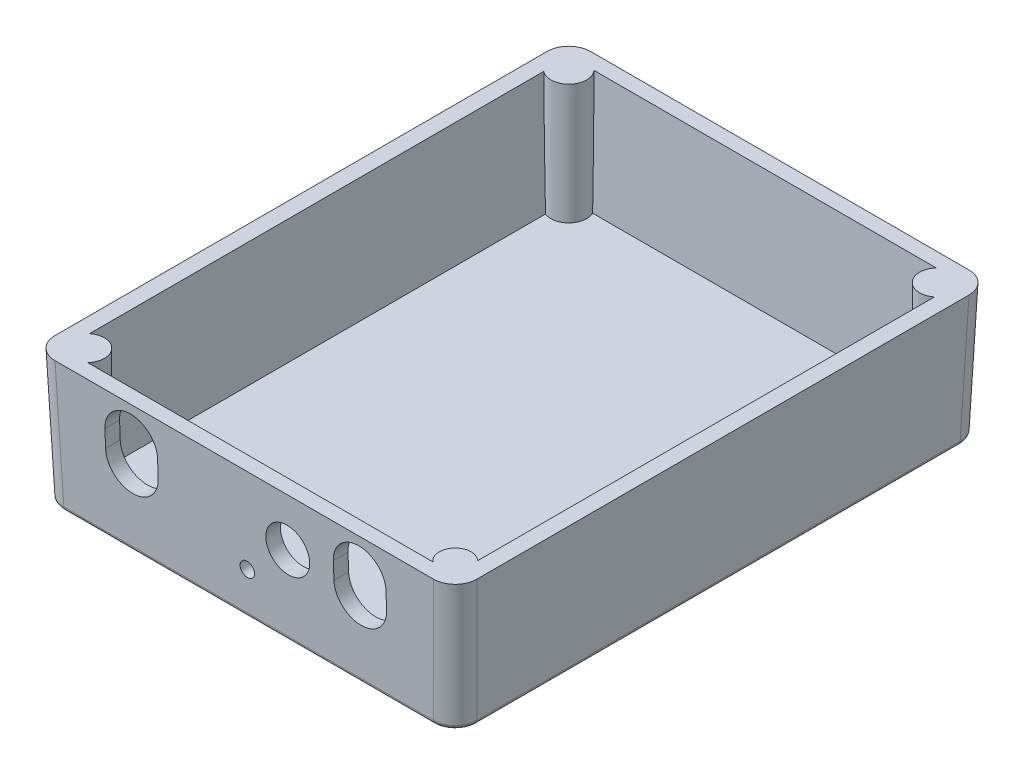
from build123d import *

# Parameters (mm, degrees)
SKETCH1_W               = 94.1
SKETCH1_H               = 120
BOSS_EXTRUDE1_DEPTH     = 29.82
BOSS_EXTRUDE1_TAPER     = -2
FILLET1_R               = 4.95
SKETCH3_W               = 89.06
SKETCH3_H               = 115.4
CUT_EXTRUDE1_DEPTH      = 27.4
CUT_EXTRUDE1_TAPER      = 2
SKETCH4_R               = 4.065
SKETCH4_R_2             = 3.612475726
BOSS_EXTRUDE2_DEPTH     = 29.82
CUT_EXTRUDE2_START      = 3
SKETCH6_R               = 6
SKETCH6_R_2             = 5
SKETCH6_R_3             = 1.65
CUT_EXTRUDE2_DEPTH      = 2.041337446
CUT_EXTRUDE2_DEPTH_BACK = 8
SKETCH8_R               = 2.625
SKETCH8_R_2             = 6.5
CUT_EXTRUDE3_DEPTH      = 5
FILLET2_R               = 1


with BuildPart() as part:
    # Sketch1 → Boss-Extrude1 (new body)
    with BuildSketch(Plane(origin=(0, 0, 0), x_dir=(1, 0, 0), z_dir=(0, 1, 0))):
        with Locations((47.05, 60)):
            Rectangle(SKETCH1_W, SKETCH1_H)
    extrude(amount=BOSS_EXTRUDE1_DEPTH, taper=BOSS_EXTRUDE1_TAPER)

    # Fillet1
    fillet1_edges = [part.edges().sort_by_distance(p)[0] for p in [
        (-0.520668673, 14.91, -120.520668673),
        (94.620668673, 14.91, -120.520668673),
        (94.620668673, 14.91, 0.520668673),
        (-0.520668673, 14.91, 0.520668673),
    ]]
    fillet(fillet1_edges, radius=FILLET1_R)

    # Sketch3 → Cut-Extrude1 (cut)
    with BuildSketch(Plane(origin=(0, 29.82, 0), x_dir=(1, 0, 0), z_dir=(0, 1, 0))):
        with Locations((47.05, 60)):
            Rectangle(SKETCH3_W, SKETCH3_H)
    extrude(amount=-CUT_EXTRUDE1_DEPTH, taper=CUT_EXTRUDE1_TAPER, mode=Mode.SUBTRACT)

    # Sketch4 → Boss-Extrude2 (add)
    with BuildSketch(Plane(origin=(0, 0, 0), x_dir=(1, 0, 0), z_dir=(0, 1, 0))):
        with Locations((5.028178417, 114.971821583)):
            Circle(SKETCH4_R)
        with Locations((89.071821583, 114.971821583)):
            Circle(SKETCH4_R)
        with Locations((5.028178417, 5.028178417)):
            Circle(SKETCH4_R)
        with Locations((89.071821583, 5.028178417)):
            Circle(SKETCH4_R_2)
    extrude(amount=BOSS_EXTRUDE2_DEPTH)

    # Sketch6 → Cut-Extrude2 (cut, two sides)
    with BuildSketch(Plane.XY.offset(CUT_EXTRUDE2_START)) as cut_extrude2_sk:
        with Locations((21.015, 17.82)):
            Circle(SKETCH6_R)
        with BuildLine():
            ThreePointArc((27.015, 21.82), (21.015, 27.82), (15.015, 21.82))
            ThreePointArc((15.015, 21.82), (15.101408642, 20.805388128), (15.358145751, 19.82))
            ThreePointArc((15.358145751, 19.82), (21.015, 23.82), (26.671854249, 19.82))
            ThreePointArc((26.671854249, 19.82), (26.928591358, 20.805388128), (27.015, 21.82))
        make_face()
        with Locations((56.575, 18.57)):
            Circle(SKETCH6_R_2)
        with Locations((73.085, 17.82)):
            Circle(SKETCH6_R)
        with BuildLine():
            ThreePointArc((79.085, 21.82), (73.085, 27.82), (67.085, 21.82))
            ThreePointArc((67.085, 21.82), (67.171408642, 20.805388128), (67.428145751, 19.82))
            ThreePointArc((67.428145751, 19.82), (73.085, 23.82), (78.741854249, 19.82))
            ThreePointArc((78.741854249, 19.82), (78.998591358, 20.805388128), (79.085, 21.82))
        make_face()
        with BuildLine():
            ThreePointArc((15.358145751, 19.82), (15.101408642, 20.805388128), (15.015, 21.82))
            Line((15.015, 21.82), (15.015, 17.82))
            ThreePointArc((15.015, 17.82), (15.101408642, 18.834611872), (15.358145751, 19.82))
        make_face()
        with BuildLine():
            Line((27.015, 17.82), (27.015, 21.82))
            ThreePointArc((27.015, 21.82), (26.928591358, 20.805388128), (26.671854249, 19.82))
            ThreePointArc((26.671854249, 19.82), (26.928591358, 18.834611872), (27.015, 17.82))
        make_face()
        with Locations((21.015, 21.82)):
            Circle(SKETCH6_R)
        with BuildLine():
            ThreePointArc((67.428145751, 19.82), (67.171408642, 20.805388128), (67.085, 21.82))
            Line((67.085, 21.82), (67.085, 17.82))
            ThreePointArc((67.085, 17.82), (67.171408642, 18.834611872), (67.428145751, 19.82))
        make_face()
        with BuildLine():
            Line((79.085, 17.82), (79.085, 21.82))
            ThreePointArc((79.085, 21.82), (78.998591358, 20.805388128), (78.741854249, 19.82))
            ThreePointArc((78.741854249, 19.82), (78.998591358, 18.834611872), (79.085, 17.82))
        make_face()
        with Locations((73.085, 21.82)):
            Circle(SKETCH6_R)
        with Locations((47.05, 9.82)):
            Circle(SKETCH6_R_3)
    extrude(amount=CUT_EXTRUDE2_DEPTH, mode=Mode.SUBTRACT)
    extrude(cut_extrude2_sk.sketch, amount=-CUT_EXTRUDE2_DEPTH_BACK, mode=Mode.SUBTRACT)

    # Sketch8 → Cut-Extrude3 (cut)
    with BuildSketch(Plane(origin=(0, 0, 0), x_dir=(-1, 0, 0), z_dir=(0, -1, 0))):
        with Locations((-71.815, 90.353)):
            Circle(SKETCH8_R)
        with Locations((-71.815, 103.053)):
            Circle(SKETCH8_R_2)
    extrude(amount=-CUT_EXTRUDE3_DEPTH, mode=Mode.SUBTRACT)

    # Fillet2
    fillet2_edges = [part.edges().sort_by_distance(p)[0] for p in [
        (94.1, 0, -60),
        (0, 0, -60),
        (47.05, 0, -120),
        (47.05, 0, 0),
        (1.448572949, 0, -118.551427051),
        (92.651427051, 0, -118.551427051),
        (1.448572949, 0, -1.448572949),
        (92.651427051, 0, -1.448572949),
    ]]
    fillet(fillet2_edges, radius=FILLET2_R)


solid = part.part
